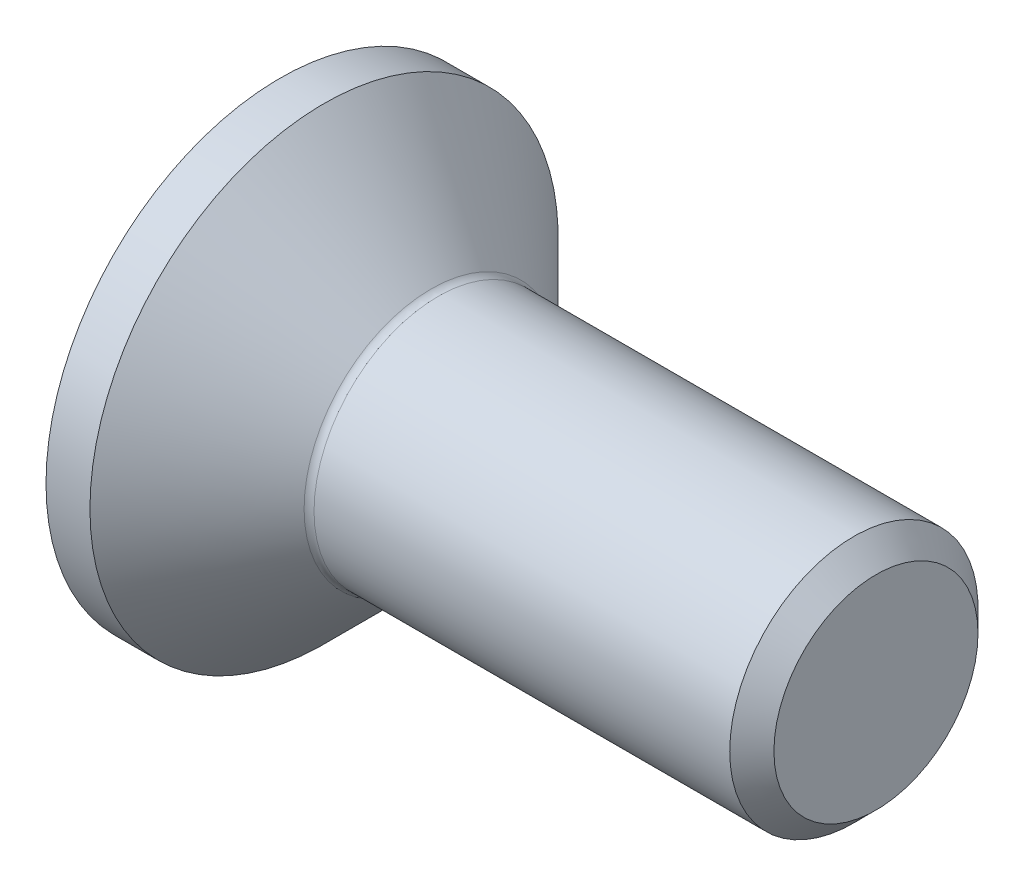
from build123d import *

# Parameters (mm, degrees)
FILLET1_R   = 0.2
HEX_2_DEPTH = 1.9


with BuildPart() as part:
    # BodySke → BaseBody (revolve)
    with BuildSketch(Plane.XY, mode=Mode.PRIVATE) as basebody_sk:
        Polygon((0, 0), (0, 4.715), (0.885, 4.715), (3.1, 2.5), (11.555, 2.5), (12, 2.055), (12, 0), align=None)
    revolve(basebody_sk.sketch.rotate(Axis((0, 0, 0), (1, 0, 0)), 90), axis=Axis((0, 0, 0), (1, 0, 0)))  # turned: the seam where the file's is

    # Fillet1
    fillet1_edges = [part.edges().sort_by_distance(p)[0] for p in [
        (3.1, 0, -2.5),
    ]]
    fillet(fillet1_edges, radius=FILLET1_R)

    # Sketch2 → PreBroach (revolve, cut)
    with BuildSketch(Plane.XY, mode=Mode.PRIVATE) as prebroach_sk:
        Polygon((0, 1.5), (1.9, 1.5), (2.766025404, 0), (0, 0), align=None)
    revolve(prebroach_sk.sketch.rotate(Axis((0, 0, 0), (1, 0, 0)), 90), axis=Axis((0, 0, 0), (1, 0, 0)), mode=Mode.SUBTRACT)  # turned: the seam where the file's is

    # Sketch3 → Hex 2 (cut)
    with BuildSketch(Plane.ZY):
        Polygon((-1.5, -0.866025404), (-1.5, 0.866025404), (0, 1.732050808), (1.5, 0.866025404), (1.5, -0.866025404), (0, -1.732050808), align=None)
    extrude(amount=-HEX_2_DEPTH, mode=Mode.SUBTRACT)


solid = part.part
